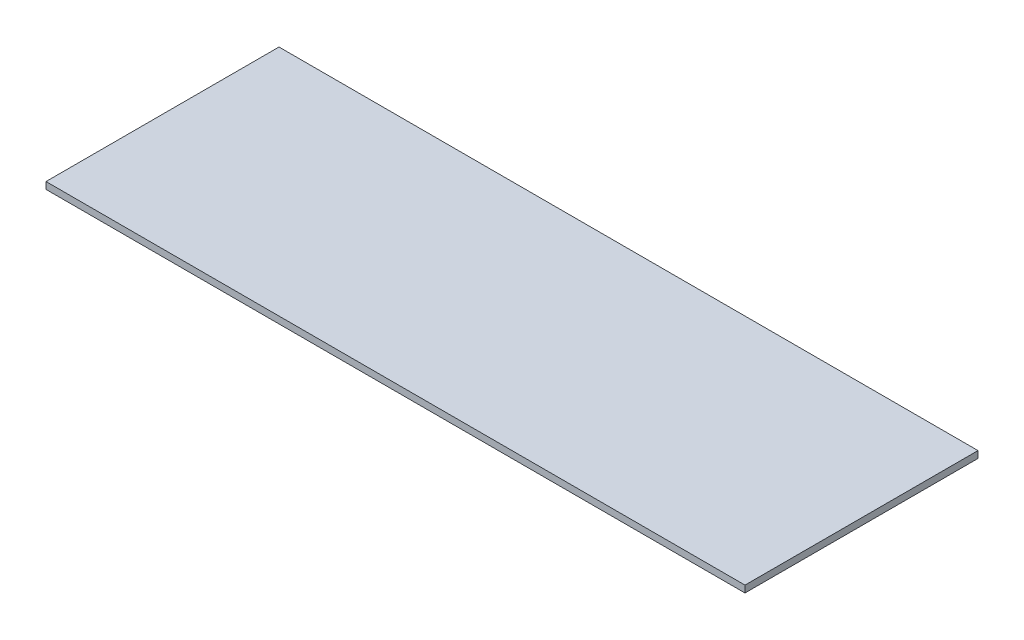
from build123d import *

# Parameters (mm, degrees)
SKETCH1_W           = 51
SKETCH1_H           = 0.5
BOSS_EXTRUDE1_DEPTH = 17


with BuildPart() as part:
    # Sketch1 → Boss-Extrude1 (new body)
    with BuildSketch(Plane.XY):
        with Locations((-25.5, -0.25)):
            Rectangle(SKETCH1_W, SKETCH1_H)
    extrude(amount=BOSS_EXTRUDE1_DEPTH)


solid = part.part
